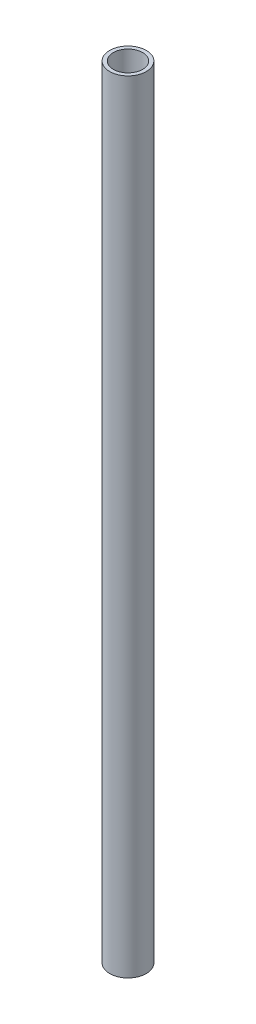
from build123d import *

# Parameters (mm, degrees)
SKETCH1_R           = 4.7625
SKETCH1_R_2         = 3.81
BOSS_EXTRUDE1_DEPTH = 203.2


with BuildPart() as part:
    # Sketch1 → Boss-Extrude1 (new body)
    with BuildSketch(Plane(origin=(0, 0, 0), x_dir=(1, 0, 0), z_dir=(0, 1, 0))):
        Circle(SKETCH1_R)
        Circle(SKETCH1_R_2, mode=Mode.SUBTRACT)
    extrude(amount=BOSS_EXTRUDE1_DEPTH)


solid = part.part
